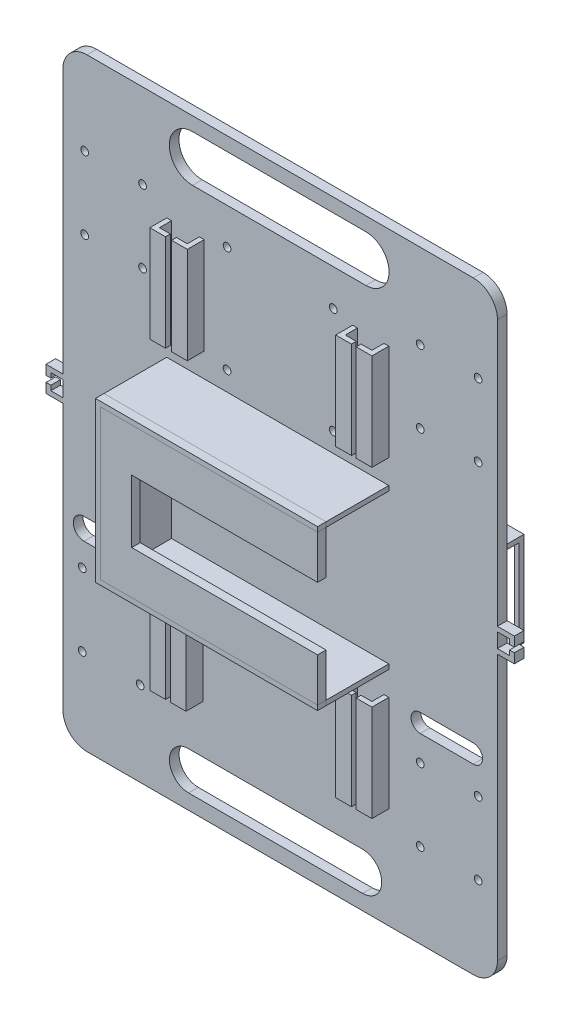
from build123d import *

# Parameters (mm, degrees)
SKETCH_2_R          = 1.6
EXTRUDE_1_DEPTH     = 4
EXTRUDE_2_DEPTH     = 26
SKETCH_5_W          = 13
SKETCH_5_H          = 26
EXTRUDE_3_DEPTH     = 3.5
EXTRUDE_4_DEPTH     = 3.5
SKETCH_7_W          = 2
SKETCH_7_H          = 40
EXTRUDE_5_DEPTH     = 5
SKETCH_8_W          = 6.5
SKETCH_8_H          = 40
EXTRUDE_6_DEPTH     = 2
SKETCH_11_W         = 2
SKETCH_11_H         = 40
EXTRUDE_7_DEPTH     = 5
SKETCH_12_W         = 2
SKETCH_12_H         = 40
EXTRUDE_8_DEPTH     = 5
SKETCH_13_W         = 6.5
SKETCH_13_H         = 40
EXTRUDE_9_DEPTH     = 2
SKETCH_14_W         = 6.5
SKETCH_14_H         = 40
EXTRUDE_10_DEPTH    = 2
SKETCH_16_R         = 1.6
CUT_EXTRUDE_1_DEPTH = 5
SKETCH_20_W         = 35
SKETCH_20_H         = 35
EXTRUDE_12_DEPTH    = 20
SKETCH_21_W         = 18
SKETCH_21_H         = 35
CUT_EXTRUDE_2_DEPTH = 60
SKETCH_22_W         = 3
SKETCH_22_H         = 35
EXTRUDE_13_DEPTH    = 1
SKETCH_23_W         = 3
SKETCH_23_H         = 35
EXTRUDE_18_DEPTH    = 1
SKETCH_24_W         = 39
SKETCH_24_H         = 39
SKETCH_24_W_2       = 35
SKETCH_24_H_2       = 35
EXTRUDE_19_DEPTH    = 20
SKETCH_25_W         = 12
SKETCH_25_H         = 32
CUT_EXTRUDE_3_DEPTH = 50
SKETCH_26_W         = 4
SKETCH_26_H         = 2
EXTRUDE_20_DEPTH    = 5
SKETCH_27_W         = 4
SKETCH_27_H         = 4
EXTRUDE_21_DEPTH    = 2
SKETCH_28_W         = 4
SKETCH_28_H         = 2
EXTRUDE_22_DEPTH    = 5
SKETCH_29_W         = 4
SKETCH_29_H         = 4
EXTRUDE_23_DEPTH    = 2
CUT_EXTRUDE_4_DEPTH = 10
CUT_EXTRUDE_5_DEPTH = 10


with BuildPart() as part:
    # 草图2 → 凸台-拉伸1 (new body)
    with BuildSketch(Plane.XY):
        with BuildLine():
            Line((-97.180739019, 63.077036811), (62.819260981, 63.077036811))
            ThreePointArc((62.819260981, 63.077036811), (69.890328793, 60.148104623), (72.819260981, 53.077036811))
            Line((72.819260981, 53.077036811), (72.819260981, -176.922963189))
            ThreePointArc((72.819260981, -176.922963189), (69.890328793, -183.994031001), (62.819260981, -186.922963189))
            Line((62.819260981, -186.922963189), (-97.180739019, -186.922963189))
            ThreePointArc((-97.180739019, -186.922963189), (-104.251806831, -183.994031001), (-107.180739019, -176.922963189))
            Line((-107.180739019, -176.922963189), (-107.180739019, 53.077036811))
            ThreePointArc((-107.180739019, 53.077036811), (-104.251806831, 60.148104623), (-97.180739019, 63.077036811))
        make_face()
        with Locations((-99.180739019, -151.922963189)):
            Circle(SKETCH_2_R, mode=Mode.SUBTRACT)
        with Locations((-99.180739019, -121.922963189)):
            Circle(SKETCH_2_R, mode=Mode.SUBTRACT)
        with Locations((-75.180739019, -121.922963189)):
            Circle(SKETCH_2_R, mode=Mode.SUBTRACT)
        with Locations((-75.180739019, -151.922963189)):
            Circle(SKETCH_2_R, mode=Mode.SUBTRACT)
        with Locations((64.819260981, -151.922963189)):
            Circle(SKETCH_2_R, mode=Mode.SUBTRACT)
        with Locations((40.819260981, -151.922963189)):
            Circle(SKETCH_2_R, mode=Mode.SUBTRACT)
        with Locations((40.819260981, -121.922963189)):
            Circle(SKETCH_2_R, mode=Mode.SUBTRACT)
        with Locations((64.819260981, -121.922963189)):
            Circle(SKETCH_2_R, mode=Mode.SUBTRACT)
        with Locations((-98.180739019, 28.077036811)):
            Circle(SKETCH_2_R, mode=Mode.SUBTRACT)
        with Locations((-98.180739019, -1.922963189)):
            Circle(SKETCH_2_R, mode=Mode.SUBTRACT)
        with Locations((-74.180739019, 28.077036811)):
            Circle(SKETCH_2_R, mode=Mode.SUBTRACT)
        with Locations((-74.180739019, -1.922963189)):
            Circle(SKETCH_2_R, mode=Mode.SUBTRACT)
        with Locations((40.819260981, 28.077036811)):
            Circle(SKETCH_2_R, mode=Mode.SUBTRACT)
        with Locations((64.819260981, 28.077036811)):
            Circle(SKETCH_2_R, mode=Mode.SUBTRACT)
        with Locations((40.819260981, -1.922963189)):
            Circle(SKETCH_2_R, mode=Mode.SUBTRACT)
        with Locations((64.819260981, -1.922963189)):
            Circle(SKETCH_2_R, mode=Mode.SUBTRACT)
    extrude(amount=EXTRUDE_1_DEPTH)

    # 草图3 → 凸台-拉伸2 (add)
    with BuildSketch(Plane.XY.offset(4)):
        Polygon((27.819260981, -30.922963189), (-62.180739019, -30.922963189), (-62.180739019, -92.922963189), (27.819260981, -92.922963189), (27.819260981, -94.922963189), (-64.180739019, -94.922963189), (-64.180739019, -28.922963189), (27.819260981, -28.922963189), align=None)
    extrude(amount=EXTRUDE_2_DEPTH)

    # 草图7 → 凸台-拉伸5 (add)
    with BuildSketch(Plane.XY.offset(4)):
        with Locations((-63.180739019, -124.922963189)):
            Rectangle(SKETCH_7_W, SKETCH_7_H)
        with Locations((-50.180739019, -124.922963189)):
            Rectangle(SKETCH_7_W, SKETCH_7_H)
        with Locations((13.819260981, -124.922963189)):
            Rectangle(SKETCH_7_W, SKETCH_7_H)
        with Locations((26.819260981, -124.922963189)):
            Rectangle(SKETCH_7_W, SKETCH_7_H)
    extrude(amount=EXTRUDE_5_DEPTH)

    # 草图8 → 凸台-拉伸6 (add)
    with BuildSketch(Plane.XY.offset(9)):
        with Locations((-60.930739019, -124.922963189)):
            Rectangle(SKETCH_8_W, SKETCH_8_H)
        with Locations((-52.430739019, -124.922963189)):
            Rectangle(SKETCH_8_W, SKETCH_8_H)
        with Locations((16.069260981, -124.922963189)):
            Rectangle(SKETCH_8_W, SKETCH_8_H)
        with Locations((24.569260981, -124.922963189)):
            Rectangle(SKETCH_8_W, SKETCH_8_H)
    extrude(amount=EXTRUDE_6_DEPTH)

    # 草图11 → 凸台-拉伸7 (add)
    with BuildSketch(Plane.XY.offset(4)):
        with Locations((-49.648958747, 1.077036811)):
            Rectangle(SKETCH_11_W, SKETCH_11_H)
        with Locations((26.819260981, 1.077036811)):
            Rectangle(SKETCH_11_W, SKETCH_11_H)
        with Locations((13.819260981, 1.077036811)):
            Rectangle(SKETCH_11_W, SKETCH_11_H)
    extrude(amount=EXTRUDE_7_DEPTH)

    # 草图12 → 凸台-拉伸8 (add)
    with BuildSketch(Plane.XY.offset(4)):
        with Locations((-63.180739019, 1.077036811)):
            Rectangle(SKETCH_12_W, SKETCH_12_H)
    extrude(amount=EXTRUDE_8_DEPTH)

    # 草图13 → 凸台-拉伸9 (add)
    with BuildSketch(Plane.XY.offset(9)):
        with Locations((-60.930739019, 1.077036811)):
            Rectangle(SKETCH_13_W, SKETCH_13_H)
    extrude(amount=EXTRUDE_9_DEPTH)

    # 草图14 → 凸台-拉伸10 (add)
    with BuildSketch(Plane.XY.offset(9)):
        with Locations((-51.898958747, 1.077036811)):
            Rectangle(SKETCH_14_W, SKETCH_14_H)
        with Locations((24.569260981, 1.077036811)):
            Rectangle(SKETCH_14_W, SKETCH_14_H)
        with Locations((16.069260981, 1.077036811)):
            Rectangle(SKETCH_14_W, SKETCH_14_H)
    extrude(amount=EXTRUDE_10_DEPTH)

    # 草图16 → 切除-拉伸1 (cut)
    with BuildSketch(Plane(origin=(0, 0, 0), x_dir=(-1, 0, 0), z_dir=(0, 0, -1))):
        with Locations((-4.819260981, 23.077036811)):
            Circle(SKETCH_16_R)
        with Locations((39.180739019, 23.077036811)):
            Circle(SKETCH_16_R)
        with Locations((39.180739019, -20.922963189)):
            Circle(SKETCH_16_R)
        with Locations((-4.819260981, -20.922963189)):
            Circle(SKETCH_16_R)
    extrude(amount=-CUT_EXTRUDE_1_DEPTH, mode=Mode.SUBTRACT)

    # 草图20 → 凸台-拉伸12 (add)
    with BuildSketch(Plane(origin=(0, 0, 0), x_dir=(-1, 0, 0), z_dir=(0, 0, -1))):
        Polygon((-22.819260981, -42.422963189), (-59.819260981, -42.422963189), (-59.819260981, -81.422963189), (-20.819260981, -81.422963189), (-20.819260981, -42.422963189), align=None)
        with Locations((-40.319260981, -61.922963189)):
            Rectangle(SKETCH_20_W, SKETCH_20_H, mode=Mode.SUBTRACT)
    extrude(amount=EXTRUDE_12_DEPTH)

    # 草图21 → 切除-拉伸2 (cut)
    with BuildSketch(Plane.ZY.offset(-20.819260981)):
        with Locations((-9, -61.922963189)):
            Rectangle(SKETCH_21_W, SKETCH_21_H)
    extrude(amount=-CUT_EXTRUDE_2_DEPTH, mode=Mode.SUBTRACT)

    # 草图22 → 凸台-拉伸13 (add)
    with BuildSketch(Plane(origin=(59.819260981, 0, 0), x_dir=(0, 0, -1), z_dir=(1, 0, 0))):
        with Locations((1.5, -61.922963189)):
            Rectangle(SKETCH_22_W, SKETCH_22_H)
    extrude(amount=-EXTRUDE_13_DEPTH)

    # 草图23 → 凸台-拉伸18 (add)
    with BuildSketch(Plane.ZY.offset(-20.819260981)):
        with Locations((-1.5, -61.922963189)):
            Rectangle(SKETCH_23_W, SKETCH_23_H)
    extrude(amount=-EXTRUDE_18_DEPTH)

    # 草图24 → 凸台-拉伸19 (add)
    with BuildSketch(Plane(origin=(0, 0, 0), x_dir=(-1, 0, 0), z_dir=(0, 0, -1))):
        with Locations((74.313659909, -61.922963189)):
            Rectangle(SKETCH_24_W, SKETCH_24_H)
        with Locations((74.680739019, -61.922963189)):
            Rectangle(SKETCH_24_W_2, SKETCH_24_H_2, mode=Mode.SUBTRACT)
    extrude(amount=EXTRUDE_19_DEPTH)

    # 草图25 → 切除-拉伸3 (cut)
    with BuildSketch(Plane.ZY.offset(93.813659909)):
        with Locations((-9, -60.422963189)):
            Rectangle(SKETCH_25_W, SKETCH_25_H)
    extrude(amount=-CUT_EXTRUDE_3_DEPTH, mode=Mode.SUBTRACT)

    # 草图26 → 凸台-拉伸20 (add)
    with BuildSketch(Plane(origin=(72.819260981, 0, 0), x_dir=(0, 0, -1), z_dir=(1, 0, 0))):
        with Locations((-2, -57.922963189)):
            Rectangle(SKETCH_26_W, SKETCH_26_H)
        with Locations((-2, -65.922963189)):
            Rectangle(SKETCH_26_W, SKETCH_26_H)
    extrude(amount=EXTRUDE_20_DEPTH)

    # 草图27 → 凸台-拉伸21 (add)
    with BuildSketch(Plane(origin=(77.819260981, 0, 0), x_dir=(0, 0, -1), z_dir=(1, 0, 0))):
        with Locations((-2, -58.922963189)):
            Rectangle(SKETCH_27_W, SKETCH_27_H)
        with Locations((-2, -64.922963189)):
            Rectangle(SKETCH_27_W, SKETCH_27_H)
    extrude(amount=EXTRUDE_21_DEPTH)

    # 草图28 → 凸台-拉伸22 (add)
    with BuildSketch(Plane.ZY.offset(107.180739019)):
        with Locations((2, -57.402028862)):
            Rectangle(SKETCH_28_W, SKETCH_28_H)
        with Locations((2, -65.922963189)):
            Rectangle(SKETCH_28_W, SKETCH_28_H)
    extrude(amount=EXTRUDE_22_DEPTH)

    # 草图29 → 凸台-拉伸23 (add)
    with BuildSketch(Plane.ZY.offset(112.180739019)):
        with Locations((2, -58.402028862)):
            Rectangle(SKETCH_29_W, SKETCH_29_H)
        with Locations((2, -64.922963189)):
            Rectangle(SKETCH_29_W, SKETCH_29_H)
    extrude(amount=EXTRUDE_23_DEPTH)

    # 草图33 → 切除-拉伸4 (cut)
    with BuildSketch(Plane.XY.offset(4)):
        with BuildLine():
            Line((-53.478478511, 57.37323989), (18.307022946, 57.37323989))
            ThreePointArc((18.307022946, 57.37323989), (27.939582246, 47.74068059), (18.307022946, 38.108121289))
            Line((18.307022946, 38.108121289), (-53.478478511, 38.108121289))
            ThreePointArc((-53.478478511, 38.108121289), (-63.111037812, 47.74068059), (-53.478478511, 57.37323989))
        make_face()
        with BuildLine():
            Line((-55.128461236, -164.815051306), (16.932082734, -164.815051306))
            ThreePointArc((16.932082734, -164.815051306), (24.86327468, -172.746243252), (16.932082734, -180.677435198))
            Line((16.932082734, -180.677435198), (-55.128461236, -180.677435198))
            ThreePointArc((-55.128461236, -180.677435198), (-63.059653182, -172.746243252), (-55.128461236, -164.815051306))
        make_face()
    extrude(amount=-CUT_EXTRUDE_4_DEPTH, mode=Mode.SUBTRACT)

    # 草图34 → 切除-拉伸5 (cut)
    with BuildSketch(Plane.XY.offset(4)):
        with BuildLine():
            Line((-98.419988723, -103.107592322), (-76.25776255, -103.107592322))
            ThreePointArc((-76.25776255, -103.107592322), (-71.799089829, -107.566265043), (-76.25776255, -112.024937764))
            Line((-76.25776255, -112.024937764), (-98.419988723, -112.024937764))
            ThreePointArc((-98.419988723, -112.024937764), (-102.878661444, -107.566265043), (-98.419988723, -103.107592322))
        make_face()
        with BuildLine():
            Line((40.829127173, -103.772257764), (62.840428219, -103.772257764))
            ThreePointArc((62.840428219, -103.772257764), (66.634435498, -107.566265043), (62.840428219, -111.360272322))
            Line((62.840428219, -111.360272322), (40.829127173, -111.360272322))
            ThreePointArc((40.829127173, -111.360272322), (37.035119894, -107.566265043), (40.829127173, -103.772257764))
        make_face()
    extrude(amount=-CUT_EXTRUDE_5_DEPTH, mode=Mode.SUBTRACT)


with BuildPart() as body_2:
    # 草图5 → 凸台-拉伸3 (new body)
    with BuildSketch(Plane.XY.offset(30)):
        Polygon((27.819260981, -48.922963189), (27.819260981, -30.922963189), (-62.180739019, -30.922963189), (-62.180739019, -48.922963189), (-49.180739019, -48.922963189), align=None)
        Polygon((27.819260981, -74.922963189), (-49.180739019, -74.922963189), (-62.180739019, -74.922963189), (-62.180739019, -92.922963189), (27.819260981, -92.922963189), align=None)
        with Locations((-55.680739019, -61.922963189)):
            Rectangle(SKETCH_5_W, SKETCH_5_H)
    extrude(amount=EXTRUDE_3_DEPTH)


with BuildPart() as body_3:
    # 草图6 → 凸台-拉伸4 (new body)
    with BuildSketch(Plane.XY.offset(33.5)):
        Polygon((27.819260981, -30.922963189), (27.819260981, -28.922963189), (-64.180739019, -28.922963189), (-64.180739019, -94.922963189), (27.819260981, -94.922963189), (27.819260981, -92.922963189), (-62.180739019, -92.922963189), (-62.180739019, -30.922963189), align=None)
    extrude(amount=-EXTRUDE_4_DEPTH)


solid = Compound([part.part, body_2.part, body_3.part])
